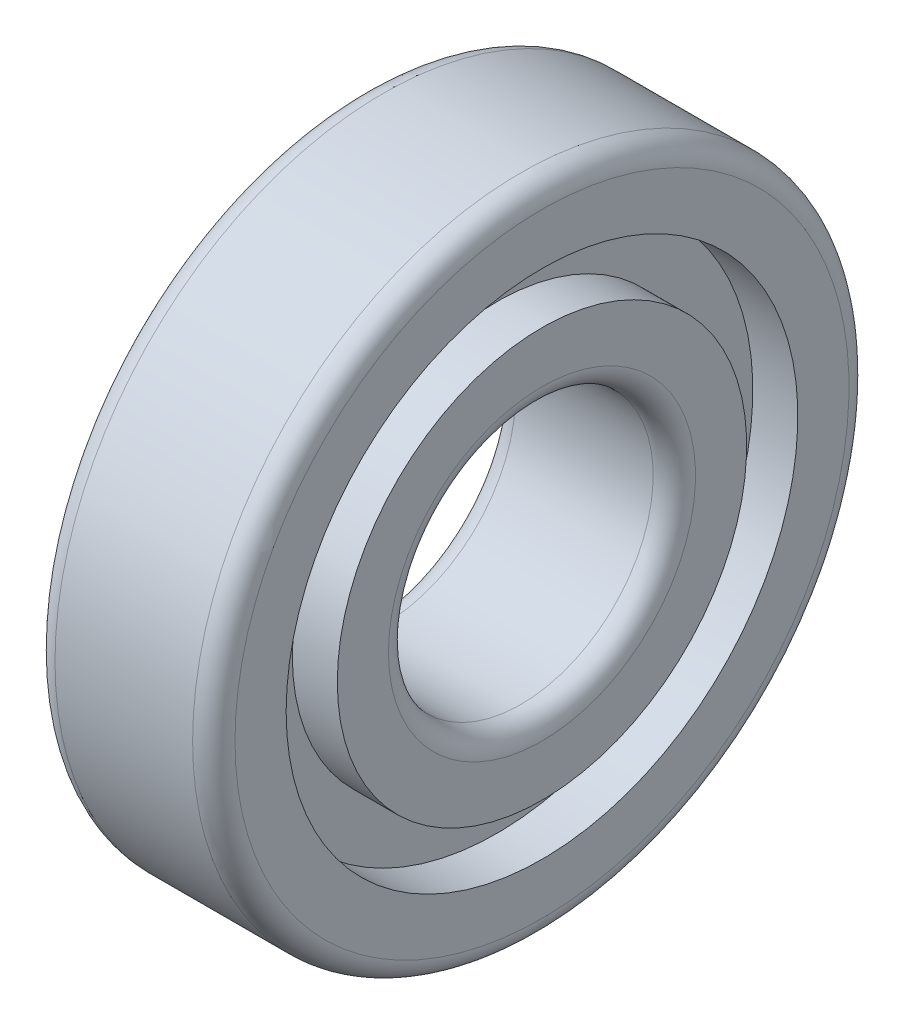
from build123d import *


with BuildPart() as part:
    # Эскиз1 → Повернуть1 (revolve)
    with BuildSketch(Plane.XY):
        with BuildLine():
            Line((6.5, 12.5), (-6.5, 12.5))
            ThreePointArc((-6.5, 12.5), (-7.914213562, 13.085786438), (-8.5, 14.5))
            Line((-8.5, 14.5), (-8.5, 19.333333333))
            Line((-8.5, 19.333333333), (-4.25, 19.333333333))
            Line((-4.25, 19.333333333), (-4.25, 24.166666667))
            Line((-4.25, 24.166666667), (-8.5, 24.166666667))
            Line((-8.5, 24.166666667), (-8.5, 29))
            ThreePointArc((-8.5, 29), (-7.914213562, 30.414213562), (-6.5, 31))
            Line((-6.5, 31), (6.5, 31))
            ThreePointArc((6.5, 31), (7.914213562, 30.414213562), (8.5, 29))
            Line((8.5, 29), (8.5, 24.166666667))
            Line((8.5, 24.166666667), (4.25, 24.166666667))
            Line((4.25, 24.166666667), (4.25, 19.333333333))
            Line((4.25, 19.333333333), (8.5, 19.333333333))
            Line((8.5, 19.333333333), (8.5, 14.5))
            ThreePointArc((8.5, 14.5), (7.914213562, 13.085786438), (6.5, 12.5))
        make_face()
    revolve(axis=Axis((-873.991742101, 0, 0), (1, 0, 0)))


solid = part.part
